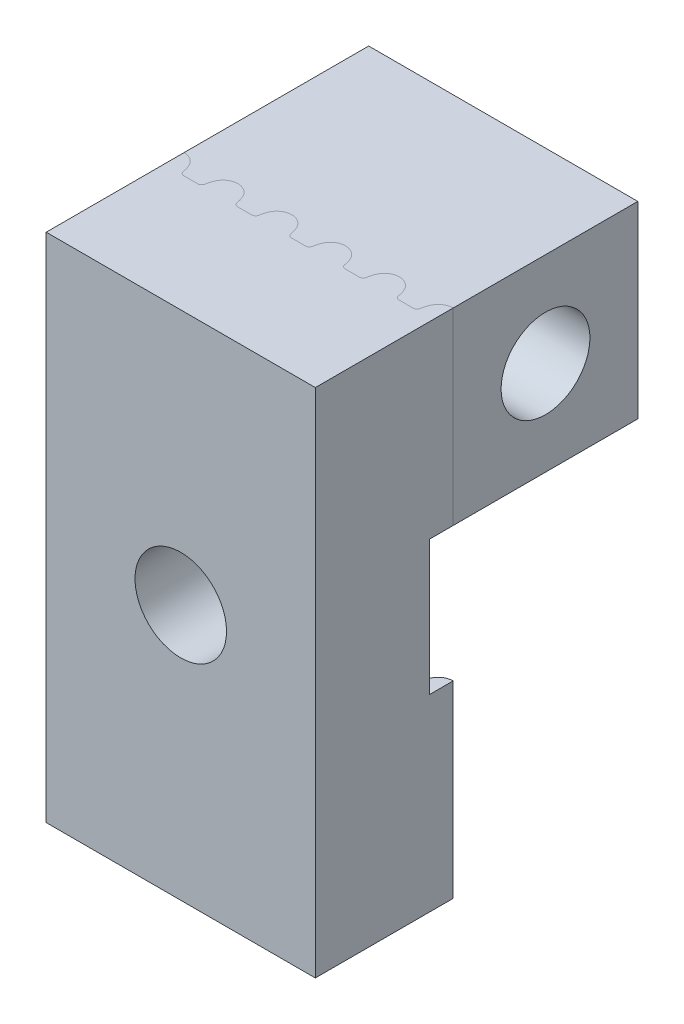
from build123d import *

# Parameters (mm, degrees)
SKETCH1_W            = 10
SKETCH1_H            = 19
BOSS_EXTRUDE1_DEPTH  = 4.25
M3_CLEARANCE_HOLE1_D = 3.4
BOSS_EXTRUDE2_DEPTH  = 7
LPATTERN1_COUNT      = 5
LPATTERN1_PITCH      = 2
MIRROR1_COPY_1_DEPTH = 7
MIRROR1_COPY_2_DEPTH = 7
MIRROR1_COPY_3_DEPTH = 7
MIRROR1_COPY_4_DEPTH = 7
BOSS_EXTRUDE4_DEPTH  = 19
SKETCH8_W            = 10
SKETCH8_H            = 5
CUT_EXTRUDE1_DEPTH   = 0.75
SKETCH11_W           = 1.7
SKETCH11_H           = 5
SKETCH12_W           = 10
SKETCH12_H           = 12
CUT_EXTRUDE2_DEPTH   = 5.75
SKETCH13_W           = 10
SKETCH13_H           = 7
BOSS_EXTRUDE5_DEPTH  = 1.86
SKETCH14_R           = 2.35
CUT_EXTRUDE3_DEPTH   = 3.8
SKETCH15_R           = 1.65
CUT_EXTRUDE4_DEPTH   = 7.2


with BuildPart() as part:
    # Sketch1 → Boss-Extrude1 (new body)
    with BuildSketch(Plane.XY):
        Rectangle(SKETCH1_W, SKETCH1_H)
    extrude(amount=BOSS_EXTRUDE1_DEPTH)

    # M3 Clearance Hole1 (through all)
    with Locations(Plane.XY.offset(4.25)):
        with Locations((0, 0)):
            Hole(M3_CLEARANCE_HOLE1_D / 2)

    # Sketch6 → Boss-Extrude2 (add)
    with BuildSketch(Plane(origin=(0, 9.5, 0), x_dir=(1, 0, 0), z_dir=(0, 1, 0))):
        with BuildLine():
            Line((-5, 0), (-3, 0))
            Line((-3, 0), (-3, 0.1225))
            Line((-3, 0.1225), (-3, 0.8725))
            ThreePointArc((-3, 0.8725), (-3.290965098, 0.790114337), (-3.495546944, 0.567416438))
            ThreePointArc((-3.495546944, 0.567416438), (-3.557616361, 0.413893607), (-3.593499348, 0.252232593))
            ThreePointArc((-3.593499348, 0.252232593), (-3.643483334, 0.15949533), (-3.742123815, 0.1225))
            Line((-3.742123815, 0.1225), (-4.257876185, 0.1225))
            ThreePointArc((-4.257876185, 0.1225), (-4.356516666, 0.15949533), (-4.406500652, 0.252232593))
            ThreePointArc((-4.406500652, 0.252232593), (-4.442383639, 0.413893607), (-4.504453056, 0.567416438))
            ThreePointArc((-4.504453056, 0.567416438), (-4.709034902, 0.790114337), (-5, 0.8725))
            Line((-5, 0.8725), (-5, 0.1225))
            Line((-5, 0.1225), (-5, 0))
        make_face()
    boss_extrude2 = extrude(amount=-BOSS_EXTRUDE2_DEPTH)

    # LPattern1: Boss-Extrude2 ×5
    with Locations(*[(i * LPATTERN1_PITCH, 0, 0) for i in range(1, LPATTERN1_COUNT)]):
        add(boss_extrude2)

    # Mirror1: Boss-Extrude2 across plane
    add(boss_extrude2.mirror(Plane.ZX))

    # Mirror1 copy 1 sketch → Mirror1 copy 1 (add)
    with BuildSketch(Plane(origin=(2, -9.5, 0), x_dir=(1, 0, 0), z_dir=(0, -1, 0))):
        with BuildLine():
            Line((-5, 0), (-3, 0))
            Line((-3, 0), (-3, -0.1225))
            Line((-3, -0.1225), (-3, -0.8725))
            ThreePointArc((-3, -0.8725), (-3.290965098, -0.790114337), (-3.495546944, -0.567416438))
            ThreePointArc((-3.495546944, -0.567416438), (-3.557616361, -0.413893607), (-3.593499348, -0.252232593))
            ThreePointArc((-3.593499348, -0.252232593), (-3.643483334, -0.15949533), (-3.742123815, -0.1225))
            Line((-3.742123815, -0.1225), (-4.257876185, -0.1225))
            ThreePointArc((-4.257876185, -0.1225), (-4.356516666, -0.15949533), (-4.406500652, -0.252232593))
            ThreePointArc((-4.406500652, -0.252232593), (-4.442383639, -0.413893607), (-4.504453056, -0.567416438))
            ThreePointArc((-4.504453056, -0.567416438), (-4.709034902, -0.790114337), (-5, -0.8725))
            Line((-5, -0.8725), (-5, -0.1225))
            Line((-5, -0.1225), (-5, 0))
        make_face()
    extrude(amount=-MIRROR1_COPY_1_DEPTH)

    # Mirror1 copy 2 sketch → Mirror1 copy 2 (add)
    with BuildSketch(Plane(origin=(4, -9.5, 0), x_dir=(1, 0, 0), z_dir=(0, -1, 0))):
        with BuildLine():
            Line((-5, 0), (-3, 0))
            Line((-3, 0), (-3, -0.1225))
            Line((-3, -0.1225), (-3, -0.8725))
            ThreePointArc((-3, -0.8725), (-3.290965098, -0.790114337), (-3.495546944, -0.567416438))
            ThreePointArc((-3.495546944, -0.567416438), (-3.557616361, -0.413893607), (-3.593499348, -0.252232593))
            ThreePointArc((-3.593499348, -0.252232593), (-3.643483334, -0.15949533), (-3.742123815, -0.1225))
            Line((-3.742123815, -0.1225), (-4.257876185, -0.1225))
            ThreePointArc((-4.257876185, -0.1225), (-4.356516666, -0.15949533), (-4.406500652, -0.252232593))
            ThreePointArc((-4.406500652, -0.252232593), (-4.442383639, -0.413893607), (-4.504453056, -0.567416438))
            ThreePointArc((-4.504453056, -0.567416438), (-4.709034902, -0.790114337), (-5, -0.8725))
            Line((-5, -0.8725), (-5, -0.1225))
            Line((-5, -0.1225), (-5, 0))
        make_face()
    extrude(amount=-MIRROR1_COPY_2_DEPTH)

    # Mirror1 copy 3 sketch → Mirror1 copy 3 (add)
    with BuildSketch(Plane(origin=(6, -9.5, 0), x_dir=(1, 0, 0), z_dir=(0, -1, 0))):
        with BuildLine():
            Line((-5, 0), (-3, 0))
            Line((-3, 0), (-3, -0.1225))
            Line((-3, -0.1225), (-3, -0.8725))
            ThreePointArc((-3, -0.8725), (-3.290965098, -0.790114337), (-3.495546944, -0.567416438))
            ThreePointArc((-3.495546944, -0.567416438), (-3.557616361, -0.413893607), (-3.593499348, -0.252232593))
            ThreePointArc((-3.593499348, -0.252232593), (-3.643483334, -0.15949533), (-3.742123815, -0.1225))
            Line((-3.742123815, -0.1225), (-4.257876185, -0.1225))
            ThreePointArc((-4.257876185, -0.1225), (-4.356516666, -0.15949533), (-4.406500652, -0.252232593))
            ThreePointArc((-4.406500652, -0.252232593), (-4.442383639, -0.413893607), (-4.504453056, -0.567416438))
            ThreePointArc((-4.504453056, -0.567416438), (-4.709034902, -0.790114337), (-5, -0.8725))
            Line((-5, -0.8725), (-5, -0.1225))
            Line((-5, -0.1225), (-5, 0))
        make_face()
    extrude(amount=-MIRROR1_COPY_3_DEPTH)

    # Mirror1 copy 4 sketch → Mirror1 copy 4 (add)
    with BuildSketch(Plane(origin=(8, -9.5, 0), x_dir=(1, 0, 0), z_dir=(0, -1, 0))):
        with BuildLine():
            Line((-5, 0), (-3, 0))
            Line((-3, 0), (-3, -0.1225))
            Line((-3, -0.1225), (-3, -0.8725))
            ThreePointArc((-3, -0.8725), (-3.290965098, -0.790114337), (-3.495546944, -0.567416438))
            ThreePointArc((-3.495546944, -0.567416438), (-3.557616361, -0.413893607), (-3.593499348, -0.252232593))
            ThreePointArc((-3.593499348, -0.252232593), (-3.643483334, -0.15949533), (-3.742123815, -0.1225))
            Line((-3.742123815, -0.1225), (-4.257876185, -0.1225))
            ThreePointArc((-4.257876185, -0.1225), (-4.356516666, -0.15949533), (-4.406500652, -0.252232593))
            ThreePointArc((-4.406500652, -0.252232593), (-4.442383639, -0.413893607), (-4.504453056, -0.567416438))
            ThreePointArc((-4.504453056, -0.567416438), (-4.709034902, -0.790114337), (-5, -0.8725))
            Line((-5, -0.8725), (-5, -0.1225))
            Line((-5, -0.1225), (-5, 0))
        make_face()
    extrude(amount=-MIRROR1_COPY_4_DEPTH)


with BuildPart() as body_2:
    # Sketch7 → Boss-Extrude4 (new body)
    with BuildSketch(Plane.XZ.offset(9.5)):
        with BuildLine():
            Line((-5, -0.8725), (-5, -5.8725))
            Line((-5, -5.8725), (5, -5.8725))
            Line((5, -5.8725), (5, -0.8725))
            ThreePointArc((5, -0.8725), (4.709034902, -0.790114337), (4.504453056, -0.567416438))
            ThreePointArc((4.504453056, -0.567416438), (4.442383639, -0.413893607), (4.406500652, -0.252232593))
            ThreePointArc((4.406500652, -0.252232593), (4.356516666, -0.15949533), (4.257876185, -0.1225))
            Line((4.257876185, -0.1225), (3.742123815, -0.1225))
            ThreePointArc((3.742123815, -0.1225), (3.643483334, -0.15949533), (3.593499348, -0.252232593))
            ThreePointArc((3.593499348, -0.252232593), (3.557616361, -0.413893607), (3.495546944, -0.567416438))
            ThreePointArc((3.495546944, -0.567416438), (3, -0.8725), (2.504453056, -0.567416438))
            ThreePointArc((2.504453056, -0.567416438), (2.442383639, -0.413893607), (2.406500652, -0.252232593))
            ThreePointArc((2.406500652, -0.252232593), (2.356516666, -0.15949533), (2.257876185, -0.1225))
            Line((2.257876185, -0.1225), (1.742123815, -0.1225))
            ThreePointArc((1.742123815, -0.1225), (1.643483334, -0.15949533), (1.593499348, -0.252232593))
            ThreePointArc((1.593499348, -0.252232593), (1.557616361, -0.413893607), (1.495546944, -0.567416438))
            ThreePointArc((1.495546944, -0.567416438), (1, -0.8725), (0.504453056, -0.567416438))
            ThreePointArc((0.504453056, -0.567416438), (0.442383639, -0.413893607), (0.406500652, -0.252232593))
            ThreePointArc((0.406500652, -0.252232593), (0.356516666, -0.15949533), (0.257876185, -0.1225))
            Line((0.257876185, -0.1225), (-0.257876185, -0.1225))
            ThreePointArc((-0.257876185, -0.1225), (-0.356516666, -0.15949533), (-0.406500652, -0.252232593))
            ThreePointArc((-0.406500652, -0.252232593), (-0.442383639, -0.413893607), (-0.504453056, -0.567416438))
            ThreePointArc((-0.504453056, -0.567416438), (-1, -0.8725), (-1.495546944, -0.567416438))
            ThreePointArc((-1.495546944, -0.567416438), (-1.557616361, -0.413893607), (-1.593499348, -0.252232593))
            ThreePointArc((-1.593499348, -0.252232593), (-1.643483334, -0.15949533), (-1.742123815, -0.1225))
            Line((-1.742123815, -0.1225), (-2.257876185, -0.1225))
            ThreePointArc((-2.257876185, -0.1225), (-2.356516666, -0.15949533), (-2.406500652, -0.252232593))
            ThreePointArc((-2.406500652, -0.252232593), (-2.442383639, -0.413893607), (-2.504453056, -0.567416438))
            ThreePointArc((-2.504453056, -0.567416438), (-3, -0.8725), (-3.495546944, -0.567416438))
            ThreePointArc((-3.495546944, -0.567416438), (-3.557616361, -0.413893607), (-3.593499348, -0.252232593))
            ThreePointArc((-3.593499348, -0.252232593), (-3.643483334, -0.15949533), (-3.742123815, -0.1225))
            Line((-3.742123815, -0.1225), (-4.257876185, -0.1225))
            ThreePointArc((-4.257876185, -0.1225), (-4.356516666, -0.15949533), (-4.406500652, -0.252232593))
            ThreePointArc((-4.406500652, -0.252232593), (-4.442383639, -0.413893607), (-4.504453056, -0.567416438))
            ThreePointArc((-4.504453056, -0.567416438), (-4.709034902, -0.790114337), (-5, -0.8725))
        make_face()
    extrude(amount=-BOSS_EXTRUDE4_DEPTH)

    # Sketch8 → Cut-Extrude1 (cut)
    with BuildSketch(Plane.XY.offset(-0.1225)):
        Rectangle(SKETCH8_W, SKETCH8_H)
    extrude(amount=-CUT_EXTRUDE1_DEPTH, mode=Mode.SUBTRACT)

    # Sketch11 → M3 Clearance Hole2 (revolve, cut)
    with BuildSketch(Plane(origin=(0, 0, -0.8725), x_dir=(0, -1, 0), z_dir=(1, 0, 0))):
        with Locations((0.85, 2.5)):
            Rectangle(SKETCH11_W, SKETCH11_H)
    revolve(axis=Axis((0, 0, 5.4775), (0, 0, -1)), mode=Mode.SUBTRACT)

    # Sketch12 → Cut-Extrude2 (cut)
    with BuildSketch(Plane.XY.offset(-0.1225)):
        with Locations((0, -3.5)):
            Rectangle(SKETCH12_W, SKETCH12_H)
    extrude(amount=-CUT_EXTRUDE2_DEPTH, mode=Mode.SUBTRACT)

    # Sketch13 → Boss-Extrude5 (add)
    with BuildSketch(Plane(origin=(0, 0, -5.8725), x_dir=(-1, 0, 0), z_dir=(0, 0, -1))):
        with Locations((0, 6)):
            Rectangle(SKETCH13_W, SKETCH13_H)
    extrude(amount=BOSS_EXTRUDE5_DEPTH)

    # Sketch14 → Cut-Extrude3 (cut)
    with BuildSketch(Plane.ZY.offset(5)):
        with Locations((-4.3025, 6)):
            Circle(SKETCH14_R)
    extrude(amount=-CUT_EXTRUDE3_DEPTH, mode=Mode.SUBTRACT)

    # Sketch15 → Cut-Extrude4 (cut, through all)
    with BuildSketch(Plane.ZY.offset(1.2)):
        with Locations((-4.3025, 6)):
            Circle(SKETCH15_R)
    extrude(amount=-CUT_EXTRUDE4_DEPTH, mode=Mode.SUBTRACT)


solid = Compound([part.part, body_2.part])
